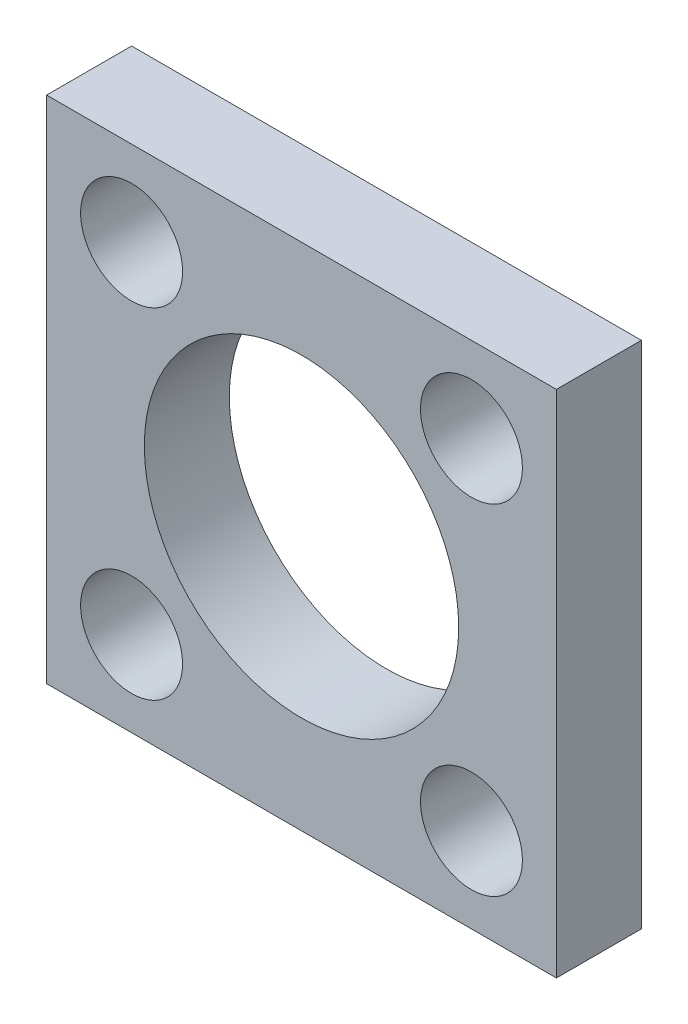
from build123d import *

# Parameters (mm, degrees)
IZIM1_W                     = 60
IZIM1_H                     = 60
IZIM1_R                     = 18.5
IZIM1_R_2                   = 6
Y_KSEKLIK_EKSTR_ZYON1_DEPTH = 10


with BuildPart() as part:
    # Çizim1 → Yükseklik-Ekstrüzyon1 (new body)
    with BuildSketch(Plane.XY):
        Rectangle(IZIM1_W, IZIM1_H)
        Circle(IZIM1_R, mode=Mode.SUBTRACT)
        with Locations((20, 20)):
            Circle(IZIM1_R_2, mode=Mode.SUBTRACT)
        with Locations((-20, 20)):
            Circle(IZIM1_R_2, mode=Mode.SUBTRACT)
        with Locations((20, -20)):
            Circle(IZIM1_R_2, mode=Mode.SUBTRACT)
        with Locations((-20, -20)):
            Circle(IZIM1_R_2, mode=Mode.SUBTRACT)
    extrude(amount=Y_KSEKLIK_EKSTR_ZYON1_DEPTH)


solid = part.part
